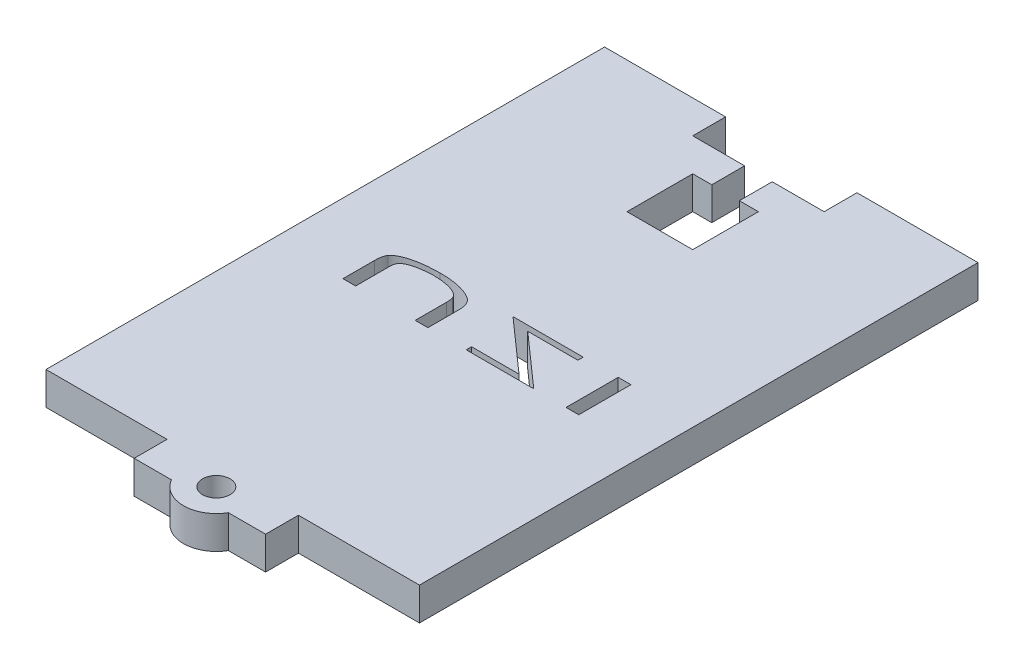
from build123d import *

# Parameters (mm, degrees)
SKETCH1_W           = 56.833752097
SKETCH1_H           = 5
BOSS_EXTRUDE1_DEPTH = 80
SKETCH2_W           = 18.416876048
SKETCH2_H           = 5
SKETCH2_W_2         = 18.416876049
BOSS_EXTRUDE2_DEPTH = 5
SKETCH3_W           = 20
SKETCH3_H           = 5
BOSS_EXTRUDE3_DEPTH = 5
CUT_EXTRUDE1_DEPTH  = 5
BOSS_EXTRUDE4_DEPTH = 5
SKETCH6_R           = 2.1
CUT_EXTRUDE2_DEPTH  = 5
SKETCH8_W           = 1.93349359
SKETCH8_H           = 7.9375
CUT_EXTRUDE3_DEPTH  = 5


with BuildPart() as part:
    # Sketch1 → Boss-Extrude1 (new body)
    with BuildSketch(Plane.XY):
        with Locations((-105.747769379, -71.943096951)):
            Rectangle(SKETCH1_W, SKETCH1_H)
    extrude(amount=BOSS_EXTRUDE1_DEPTH)

    # Sketch2 → Boss-Extrude2 (add)
    with BuildSketch(Plane(origin=(0, 0, 0), x_dir=(-1, 0, 0), z_dir=(0, 0, -1))):
        with Locations((86.539331354, -71.943096951)):
            Rectangle(SKETCH2_W, SKETCH2_H)
        with Locations((124.956207403, -71.943096951)):
            Rectangle(SKETCH2_W_2, SKETCH2_H)
    extrude(amount=BOSS_EXTRUDE2_DEPTH)

    # Sketch3 → Boss-Extrude3 (add)
    with BuildSketch(Plane.XY.offset(80)):
        with Locations((-105.747769378, -71.943096951)):
            Rectangle(SKETCH3_W, SKETCH3_H)
    extrude(amount=BOSS_EXTRUDE3_DEPTH)

    # Sketch4 → Cut-Extrude1 (cut)
    with BuildSketch(Plane.XZ.offset(74.443096951)):
        Polygon((-107.847769378, 0), (-107.847769378, 5), (-110.747769378, 5), (-110.747769378, 15), (-100.747769378, 15), (-100.747769378, 5), (-103.647769378, 5), (-103.647769378, 0), align=None)
    extrude(amount=-CUT_EXTRUDE1_DEPTH, mode=Mode.SUBTRACT)

    # Sketch5 → Boss-Extrude4 (add)
    with BuildSketch(Plane.XZ.offset(74.443096951)):
        with BuildLine():
            Line((-110.077896397, 85), (-101.417642359, 85))
            ThreePointArc((-101.417642359, 85), (-105.747769378, 87.5), (-110.077896397, 85))
        make_face()
    extrude(amount=-BOSS_EXTRUDE4_DEPTH)

    # Sketch6 → Cut-Extrude2 (cut)
    with BuildSketch(Plane.XZ.offset(74.443096951)):
        with Locations((-105.747769378, 82.5)):
            Circle(SKETCH6_R)
    extrude(amount=-CUT_EXTRUDE2_DEPTH, mode=Mode.SUBTRACT)

    # Sketch8 → Cut-Extrude3 (cut)
    with BuildSketch(Plane.XZ.offset(74.443096951)):
        with BuildLine():
            Line((-123.535910404, 45.4375), (-121.602416814, 45.4375))
            Line((-121.602416814, 45.4375), (-121.602416814, 40.681678185))
            add(Edge.make_bspline(
                [(-121.602416814, 40.681678185), (-121.601990048, 40.614365441), (-121.601180152, 40.486622809), (-121.598439266, 40.304791606), (-121.592462111, 40.143061597), (-121.582649953, 40.001032923), (-121.57194051, 39.879023265), (-121.55953718, 39.776587793), (-121.545409362, 39.693656046), (-121.529735909, 39.646438596), (-121.522914611, 39.625888922)],
                knots=[0, 0, 0, 0, 0.000201942, 0.000383235, 0.000545544, 0.000687379, 0.000810317, 0.000912872, 0.000997069, 0.00106195, 0.00106195, 0.00106195, 0.00106195], degree=3))
            add(Edge.make_bspline(
                [(-121.522914611, 39.625888922), (-121.509452841, 39.587377666), (-121.482681561, 39.510790729), (-121.426995401, 39.4013048), (-121.360408578, 39.295994704), (-121.28006619, 39.19616361), (-121.189648325, 39.099739524), (-121.084644905, 39.011371702), (-120.970198973, 38.924768446), (-120.841762659, 38.843010088), (-120.697710316, 38.767120374), (-120.537215044, 38.693859228), (-120.359436668, 38.621836124), (-120.162385483, 38.55659879), (-119.948353328, 38.492219896), (-119.716163536, 38.433044528), (-119.466897465, 38.373285603), (-119.110484454, 38.302421294), (-118.652583447, 38.225640947), (-118.096617037, 38.158746344), (-117.538892715, 38.117643369), (-117.166262368, 38.112930622), (-116.980158701, 38.110576923)],
                knots=[0, 0, 0, 0, 0.000122268, 0.000243153, 0.000367543, 0.00049543, 0.00062702, 0.00076344, 0.000906544, 0.001057397, 0.001219582, 0.001394602, 0.001586524, 0.001794692, 0.002017049, 0.002256929, 0.002513405, 0.002785948, 0.003346916, 0.003905845, 0.004465364, 0.005023615, 0.005023615, 0.005023615, 0.005023615], degree=3))
            add(Edge.make_bspline(
                [(-116.980158701, 38.110576923), (-116.820057773, 38.113012249), (-116.502227103, 38.117846831), (-116.03087379, 38.147408488), (-115.569601956, 38.201435841), (-115.122201733, 38.270116147), (-114.698159331, 38.362899945), (-114.30504593, 38.466328223), (-113.950231341, 38.591770142), (-113.631201908, 38.728435362), (-113.34875012, 38.881571653), (-113.10835998, 39.053804153), (-112.902793753, 39.238379234), (-112.797305407, 39.38023024), (-112.745871341, 39.44939403)],
                knots=[0, 0, 0, 0, 0.000480322, 0.000953531, 0.00141604, 0.001873246, 0.002310797, 0.00271773, 0.003091874, 0.003438668, 0.003758203, 0.004053391, 0.004324543, 0.004582552, 0.004582552, 0.004582552, 0.004582552], degree=3))
            add(Edge.make_bspline(
                [(-112.745871341, 39.44939403), (-112.729005179, 39.477013683), (-112.692593547, 39.536640564), (-112.655395728, 39.644154214), (-112.620539489, 39.768801799), (-112.591731131, 39.913330101), (-112.572660575, 40.077680361), (-112.556459045, 40.261639349), (-112.547195392, 40.4653388), (-112.546098513, 40.607467269), (-112.545525789, 40.681678185)],
                knots=[0, 0, 0, 0, 9.6836e-05, 0.000209055, 0.000339449, 0.000485387, 0.000650461, 0.00083559, 0.001039339, 0.001261968, 0.001261968, 0.001261968, 0.001261968], degree=3))
            Line((-112.545525789, 40.681678185), (-112.545525789, 45.4375))
            Line((-112.545525789, 45.4375), (-110.612032199, 45.4375))
            Line((-110.612032199, 45.4375), (-110.612032199, 40.643517127))
            add(Edge.make_bspline(
                [(-110.612032199, 40.643517127), (-110.613477985, 40.557066925), (-110.616304371, 40.388064256), (-110.640769365, 40.140467174), (-110.679895535, 39.905487365), (-110.735004886, 39.682744005), (-110.809098914, 39.474292467), (-110.896164276, 39.27658251), (-111.0014758, 39.092896663), (-111.122090727, 38.918520772), (-111.268585123, 38.754239806), (-111.446943017, 38.599798583), (-111.654606494, 38.447346515), (-111.896614725, 38.305011699), (-112.166840551, 38.161605162), (-112.472452702, 38.030539583), (-112.807571473, 37.899478019), (-113.173034335, 37.776537822), (-113.564411059, 37.663960183), (-113.977877444, 37.566073163), (-114.411114346, 37.481431072), (-114.864742005, 37.413412032), (-115.339029089, 37.361729677), (-115.833216674, 37.323441827), (-116.347647026, 37.301283236), (-116.697109796, 37.298097825), (-116.875215793, 37.296474359)],
                knots=[0, 0, 0, 0, 0.000259299, 0.000506907, 0.000745568, 0.000973483, 0.001194247, 0.001408484, 0.001620694, 0.001828461, 0.002043564, 0.002279004, 0.00253502, 0.002815347, 0.003120457, 0.003452228, 0.003812172, 0.004199846, 0.00460849, 0.005033493, 0.005474119, 0.005932411, 0.00640914, 0.006905114, 0.007419181, 0.007953495, 0.007953495, 0.007953495, 0.007953495], degree=3))
            add(Edge.make_bspline(
                [(-116.875215793, 37.296474359), (-117.06868425, 37.298263057), (-117.448310552, 37.301772862), (-118.007268603, 37.321598277), (-118.54476417, 37.359249175), (-119.061557452, 37.406637359), (-119.556559089, 37.473190008), (-120.031185303, 37.549344646), (-120.484280367, 37.644235623), (-120.914952743, 37.748913991), (-121.317062778, 37.867570667), (-121.686773306, 37.99560829), (-122.022012304, 38.133781626), (-122.322535304, 38.280698867), (-122.589545148, 38.436491218), (-122.820107968, 38.603041936), (-123.018555474, 38.777795338), (-123.126131339, 38.907884929), (-123.178150488, 38.970790765)],
                knots=[0, 0, 0, 0, 0.000580421, 0.001138909, 0.001677586, 0.002196696, 0.002695479, 0.003175675, 0.003638446, 0.004083865, 0.004504975, 0.004895702, 0.005257132, 0.005592062, 0.005898574, 0.006183231, 0.006444425, 0.006688987, 0.006688987, 0.006688987, 0.006688987], degree=3))
            add(Edge.make_bspline(
                [(-123.178150488, 38.970790765), (-123.207601979, 39.012390462), (-123.269314795, 39.099558693), (-123.338519525, 39.254004353), (-123.400520367, 39.428804251), (-123.451403362, 39.627250965), (-123.487616881, 39.848734436), (-123.517131787, 40.092676277), (-123.531645378, 40.360316763), (-123.534449497, 40.546512034), (-123.535910404, 40.643517127)],
                knots=[0, 0, 0, 0, 0.000152586, 0.00031973, 0.000505303, 0.000708928, 0.000933214, 0.001178169, 0.001445769, 0.001736816, 0.001736816, 0.001736816, 0.001736816], degree=3))
            Line((-123.535910404, 40.643517127), (-123.535910404, 45.4375))
        make_face()
        Polygon((-104.781022583, 44.623397436), (-104.781022583, 45.4375), (-94.502977712, 45.4375), (-102.539060444, 38.314102564), (-94.910028994, 38.314102564), (-94.910028994, 37.5), (-105.595125148, 37.5), (-97.557452371, 44.623397436), align=None)
        with Locations((-88.621086686, 41.46875)):
            Rectangle(SKETCH8_W, SKETCH8_H)
    extrude(amount=-CUT_EXTRUDE3_DEPTH, mode=Mode.SUBTRACT)


solid = part.part
